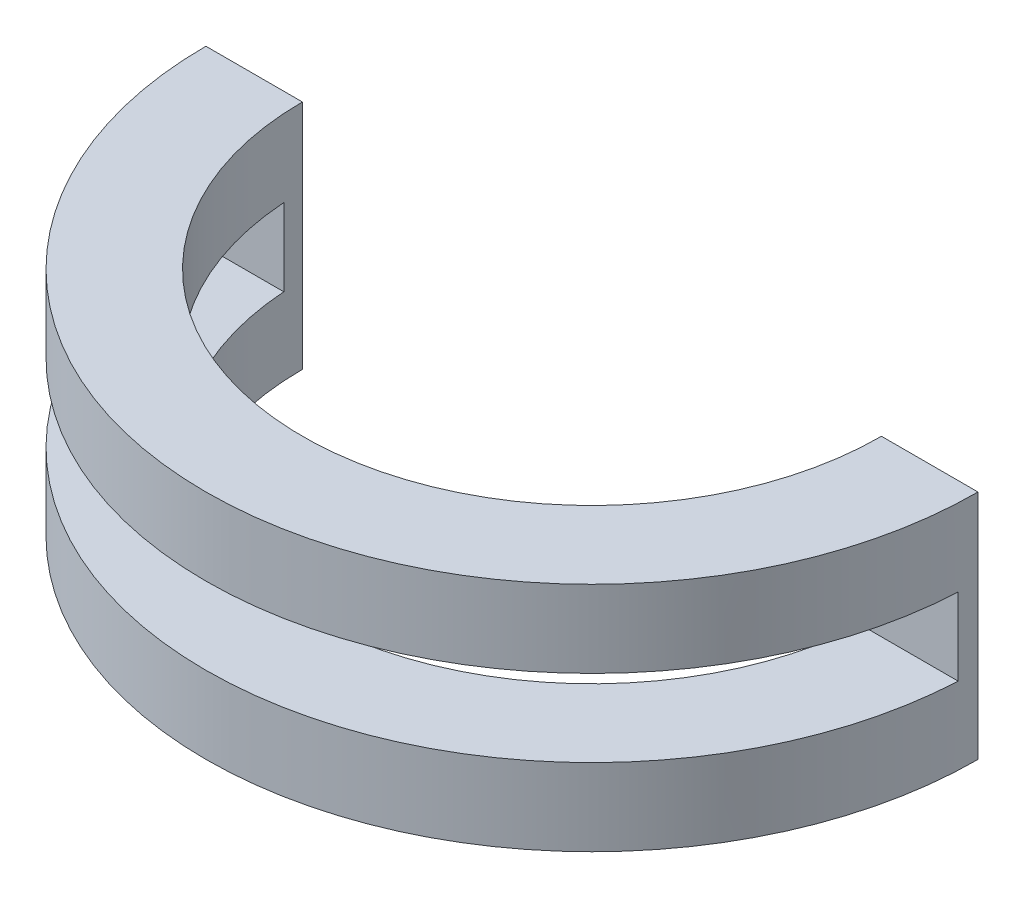
from build123d import *

# Parameters (mm, degrees)
BOSS_EXTRUDE1_DEPTH     = 60
CUT_EXTRUDE4_DEPTH      = 10
CUT_EXTRUDE4_DEPTH_BACK = 10


with BuildPart() as part:
    # Sketch2 → Boss-Extrude1 (new body)
    with BuildSketch(Plane(origin=(0, 0, 0), x_dir=(1, 0, 0), z_dir=(0, 1, 0))):
        with BuildLine():
            Line((-100, 0), (-75, 0))
            ThreePointArc((-75, 0), (0, -75), (75, 0))
            Line((75, 0), (100, 0))
            ThreePointArc((100, 0), (0, -100), (-100, 0))
        make_face()
    extrude(amount=BOSS_EXTRUDE1_DEPTH)

    # Sketch4 → Cut-Extrude4 (cut, two sides)
    with BuildSketch(Plane(origin=(0, 30, 0), x_dir=(1, 0, 0), z_dir=(0, 1, 0))) as cut_extrude4_sk:
        with BuildLine():
            Line((-99.874921777, -5), (-74.833147735, -5))
            ThreePointArc((-74.833147735, -5), (0, -75), (74.833147735, -5))
            Line((74.833147735, -5), (99.874921777, -5))
            ThreePointArc((99.874921777, -5), (0, -100), (-99.874921777, -5))
        make_face()
    extrude(amount=CUT_EXTRUDE4_DEPTH, mode=Mode.SUBTRACT)
    extrude(cut_extrude4_sk.sketch, amount=-CUT_EXTRUDE4_DEPTH_BACK, mode=Mode.SUBTRACT)


solid = part.part
